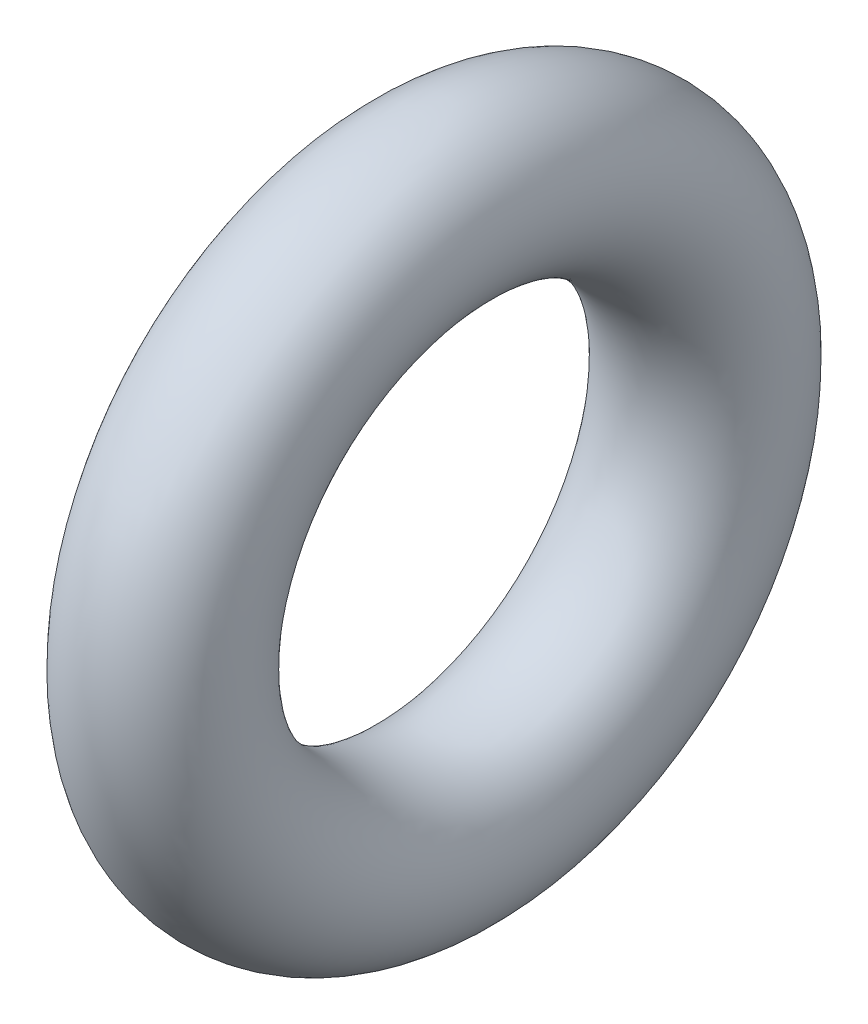
from build123d import *

# Parameters (mm, degrees)
SKIZZE1_R = 1.3


with BuildPart() as part:
    # Skizze1 → Rotation1 (revolve)
    with BuildSketch(Plane.XY):
        with Locations((0, 4.3)):
            Circle(SKIZZE1_R)
    revolve(axis=Axis((-5.518776228, 0, 0), (-1, 0, 0)))


solid = part.part
